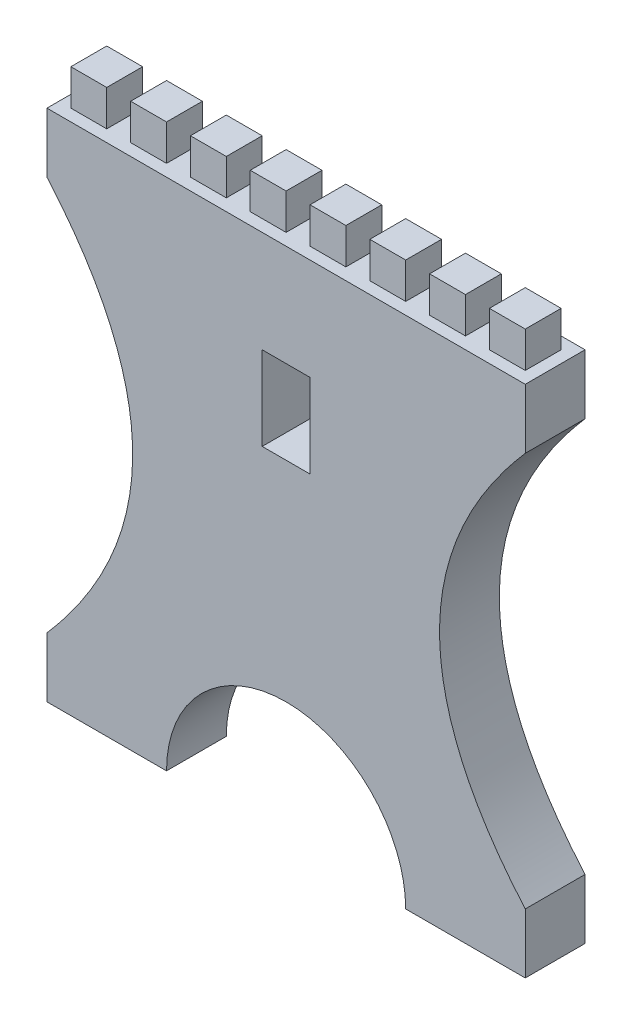
from build123d import *

# Parameters (mm, degrees)
SKETCH_1_W      = 40
SKETCH_1_H      = 70
EXTRUDE_3_DEPTH = 50
SKETCH_6_W      = 30
SKETCH_6_H      = 30
EXTRUDE_6_DEPTH = 30


with BuildPart() as part:
    # Эскиз1 → Бобышка-Вытянуть3 (new body)
    with BuildSketch(Plane.XY):
        with BuildLine():
            Line((-100, -215), (-200, -215))
            Line((-200, -215), (-200, -165))
            add(Edge.make_bspline(
                [(-200, 165), (-56.658015908, 0), (-200, -165)],
                knots=[0, 0, 0, 1, 1, 1], degree=2))
            Line((-200, 165), (-200, 215))
            Line((-200, 215), (0, 215))
            Line((0, 215), (200, 215))
            Line((200, 215), (200, 165))
            add(Edge.make_bspline(
                [(200, 165), (56.658015908, 0), (200, -165)],
                knots=[0, 0, 0, 1, 1, 1], degree=2))
            Line((200, -165), (200, -215))
            Line((200, -215), (100, -215))
            ThreePointArc((100, -215), (0, -115), (-100, -215))
        make_face()
        with Locations((0, 95)):
            Rectangle(SKETCH_1_W, SKETCH_1_H, mode=Mode.SUBTRACT)
    extrude(amount=EXTRUDE_3_DEPTH)

    # Эскиз6 → Бобышка-Вытянуть6 (add)
    with BuildSketch(Plane(origin=(0, 215, 0), x_dir=(1, 0, 0), z_dir=(0, 1, 0))):
        with Locations((-175, -25)):
            Rectangle(SKETCH_6_W, SKETCH_6_H)
        with Locations((-125, -25)):
            Rectangle(SKETCH_6_W, SKETCH_6_H)
        with Locations((-75, -25)):
            Rectangle(SKETCH_6_W, SKETCH_6_H)
        with Locations((-25, -25)):
            Rectangle(SKETCH_6_W, SKETCH_6_H)
        with Locations((25, -25)):
            Rectangle(SKETCH_6_W, SKETCH_6_H)
        with Locations((75, -25)):
            Rectangle(SKETCH_6_W, SKETCH_6_H)
        with Locations((125, -25)):
            Rectangle(SKETCH_6_W, SKETCH_6_H)
        with Locations((175, -25)):
            Rectangle(SKETCH_6_W, SKETCH_6_H)
    extrude(amount=EXTRUDE_6_DEPTH)


solid = part.part
